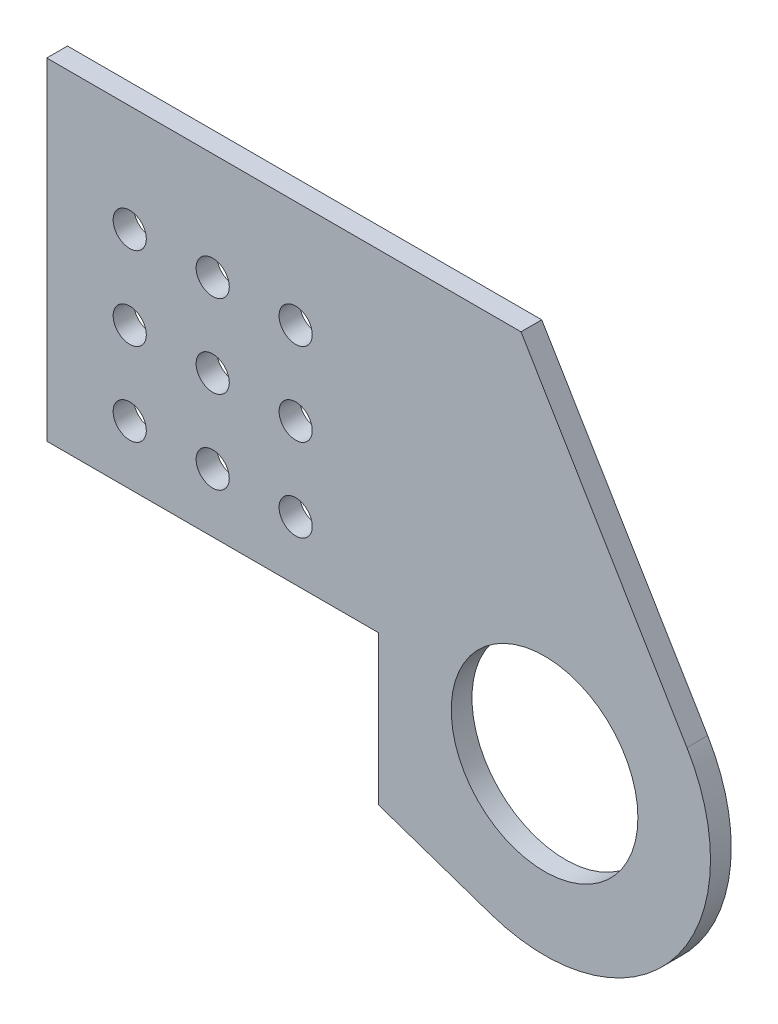
from build123d import *

# Parameters (mm, degrees)
SKETCH1_R           = 2.54
SKETCH1_R_2         = 14.2875
BOSS_EXTRUDE1_DEPTH = 3.175


with BuildPart() as part:
    # Sketch1 → Boss-Extrude1 (new body)
    with BuildSketch(Plane.XY):
        with BuildLine():
            Line((0, 0), (0, 50.8))
            Line((0, 50.8), (72.591943157, 50.8))
            Line((72.591943157, 50.8), (97.991943157, 8.381133577))
            ThreePointArc((97.991943157, 8.381133577), (95.945608162, -20.644868853), (67.98549449, -28.702681675))
            Line((67.98549449, -28.702681675), (50.8, -22.829153204))
            Line((50.8, -22.829153204), (50.8, 0))
            Line((50.8, 0), (0, 0))
        make_face()
        with Locations((12.7, 34.42794066)):
            Circle(SKETCH1_R, mode=Mode.SUBTRACT)
        with Locations((25.4, 34.42794066)):
            Circle(SKETCH1_R, mode=Mode.SUBTRACT)
        with Locations((38.1, 34.42794066)):
            Circle(SKETCH1_R, mode=Mode.SUBTRACT)
        with Locations((25.4, 21.72794066)):
            Circle(SKETCH1_R, mode=Mode.SUBTRACT)
        with Locations((38.1, 21.72794066)):
            Circle(SKETCH1_R, mode=Mode.SUBTRACT)
        with Locations((25.4, 9.02794066)):
            Circle(SKETCH1_R, mode=Mode.SUBTRACT)
        with Locations((38.1, 9.02794066)):
            Circle(SKETCH1_R, mode=Mode.SUBTRACT)
        with Locations((12.7, 21.72794066)):
            Circle(SKETCH1_R, mode=Mode.SUBTRACT)
        with Locations((12.7, 9.02794066)):
            Circle(SKETCH1_R, mode=Mode.SUBTRACT)
        with Locations((76.2, -4.667667649)):
            Circle(SKETCH1_R_2, mode=Mode.SUBTRACT)
    extrude(amount=BOSS_EXTRUDE1_DEPTH)


solid = part.part
